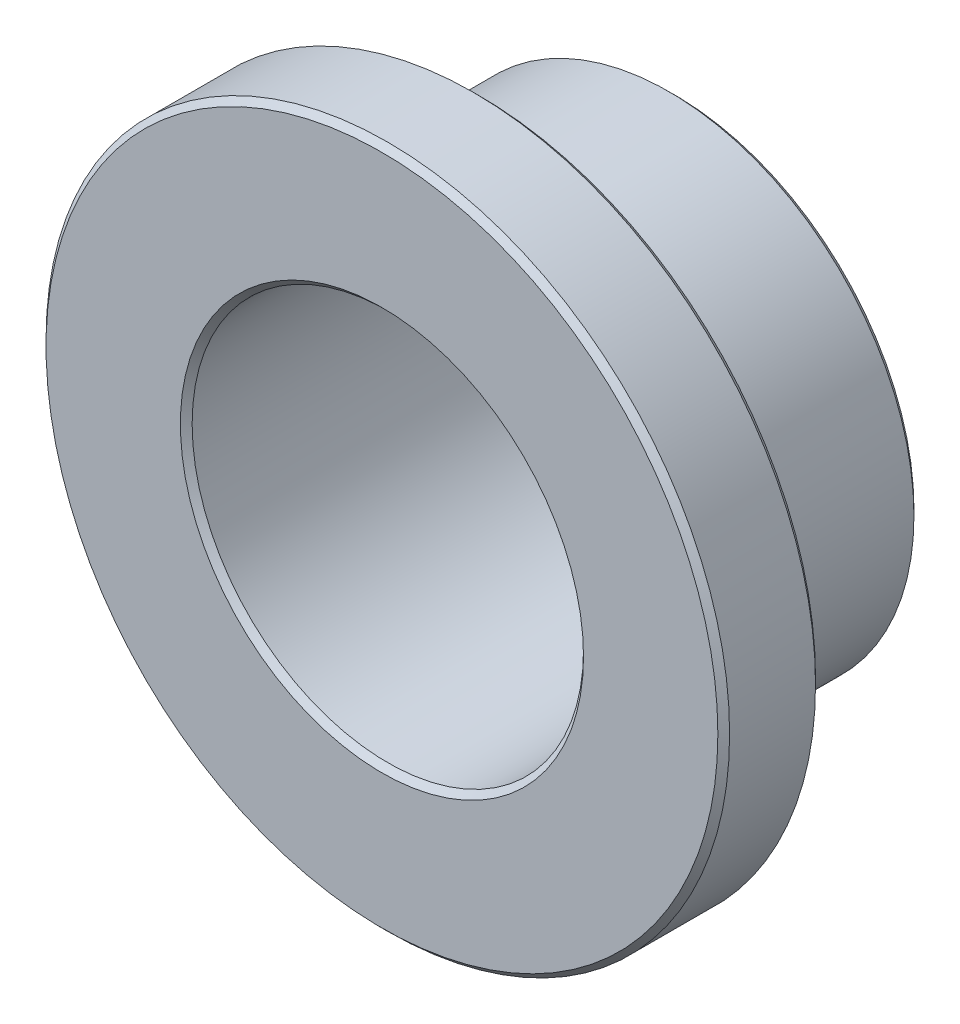
from build123d import *

# Parameters (mm, degrees)
BOSS_EXTRUDE1_START = 4.7625
SKETCH3_R           = 11.1125
SKETCH3_R_2         = 6.3627
BOSS_EXTRUDE1_DEPTH = 3.175
BOSS_EXTRUDE2_START = 1.5875
SKETCH4_R           = 7.9629
SKETCH4_R_2         = 6.3627
BOSS_EXTRUDE2_DEPTH = 6.35
CHAMFER1_SIZE       = 0.190881


with BuildPart() as part:
    # Sketch3 → Boss-Extrude1 (new body)
    with BuildSketch(Plane.XY.offset(BOSS_EXTRUDE1_START)):
        Circle(SKETCH3_R)
        Circle(SKETCH3_R_2, mode=Mode.SUBTRACT)
    extrude(amount=-BOSS_EXTRUDE1_DEPTH)

    # Sketch4 → Boss-Extrude2 (add)
    with BuildSketch(Plane.XY.offset(BOSS_EXTRUDE2_START)):
        Circle(SKETCH4_R)
        Circle(SKETCH4_R_2, mode=Mode.SUBTRACT)
    extrude(amount=-BOSS_EXTRUDE2_DEPTH)

    # Chamfer1
    chamfer1_edges = [part.edges().sort_by_distance(p)[0] for p in [
        (-6.3627, 0, -4.7625),
        (-7.9629, 0, 1.5875),
        (-11.1125, 0, 4.7625),
        (-11.1125, 0, 1.5875),
        (-6.3627, 0, 4.7625),
        (-7.9629, 0, -4.7625),
    ]]
    chamfer(chamfer1_edges, length=CHAMFER1_SIZE)


solid = part.part
